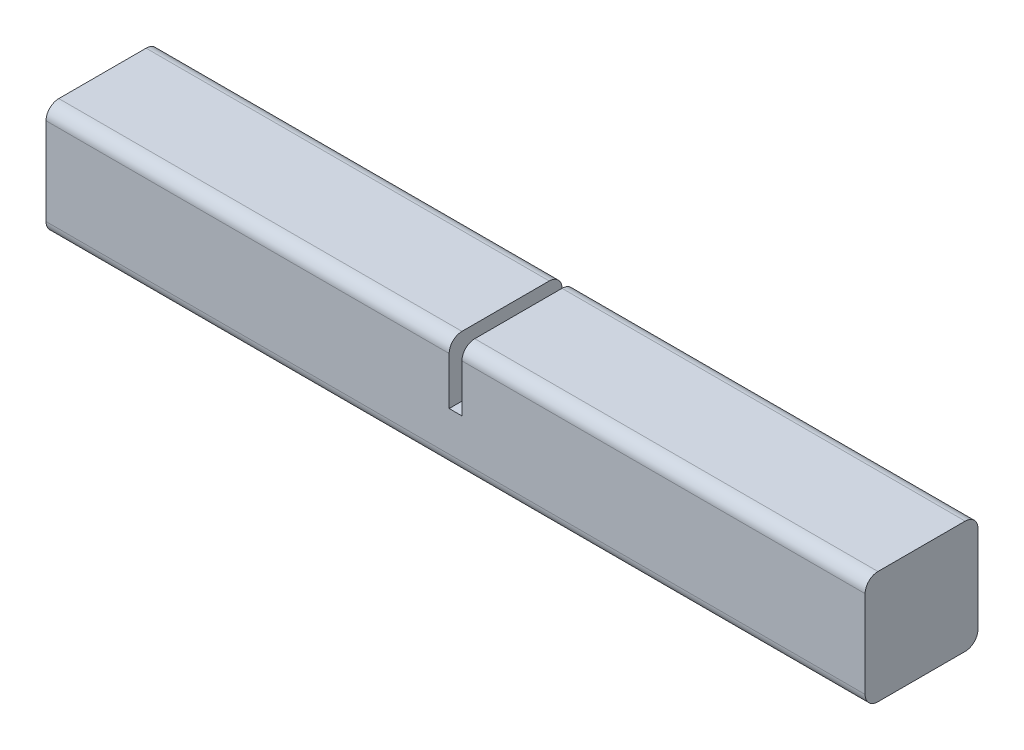
from build123d import *

# Parameters (mm, degrees)
SKETCH1_W           = 28
SKETCH1_H           = 28
BOSS_EXTRUDE1_DEPTH = 203.2
SKETCH2_W           = 3.175
SKETCH2_H           = 28
CUT_EXTRUDE1_DEPTH  = 15
FILLET1_R           = 3.175


with BuildPart() as part:
    # Sketch1 → Boss-Extrude1 (new body)
    with BuildSketch(Plane(origin=(0, 0, 0), x_dir=(0, 0, -1), z_dir=(1, 0, 0))):
        Rectangle(SKETCH1_W, SKETCH1_H)
    extrude(amount=BOSS_EXTRUDE1_DEPTH)

    # Sketch2 → Cut-Extrude1 (cut)
    with BuildSketch(Plane(origin=(0, 14, 0), x_dir=(1, 0, 0), z_dir=(0, 1, 0))):
        with Locations((101.6, 0)):
            Rectangle(SKETCH2_W, SKETCH2_H)
    extrude(amount=-CUT_EXTRUDE1_DEPTH, mode=Mode.SUBTRACT)

    # Fillet1
    fillet1_edges = [part.edges().sort_by_distance(p)[0] for p in [
        (50.00625, 14, 14),
        (50.00625, 14, -14),
        (153.19375, 14, 14),
        (153.19375, 14, -14),
        (101.6, -14, -14),
        (101.6, -14, 14),
    ]]
    fillet(fillet1_edges, radius=FILLET1_R)


solid = part.part
